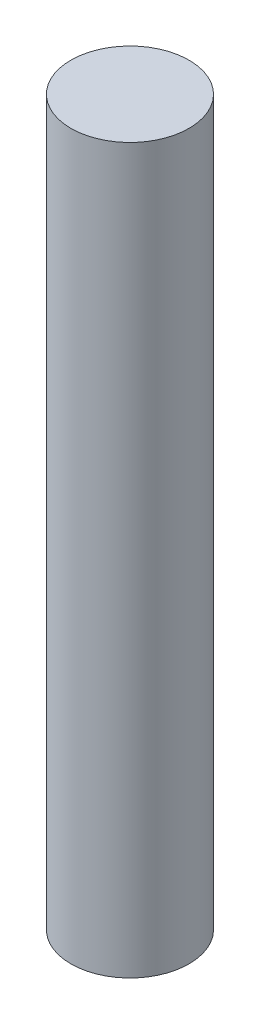
from build123d import *

# Parameters (mm, degrees)
SKETCH1_R           = 0.245
BOSS_EXTRUDE1_DEPTH = 3


with BuildPart() as part:
    # Sketch1 → Boss-Extrude1 (new body)
    with BuildSketch(Plane(origin=(0, 0, 0), x_dir=(1, 0, 0), z_dir=(0, 1, 0))):
        Circle(SKETCH1_R)
    extrude(amount=BOSS_EXTRUDE1_DEPTH)


solid = part.part
